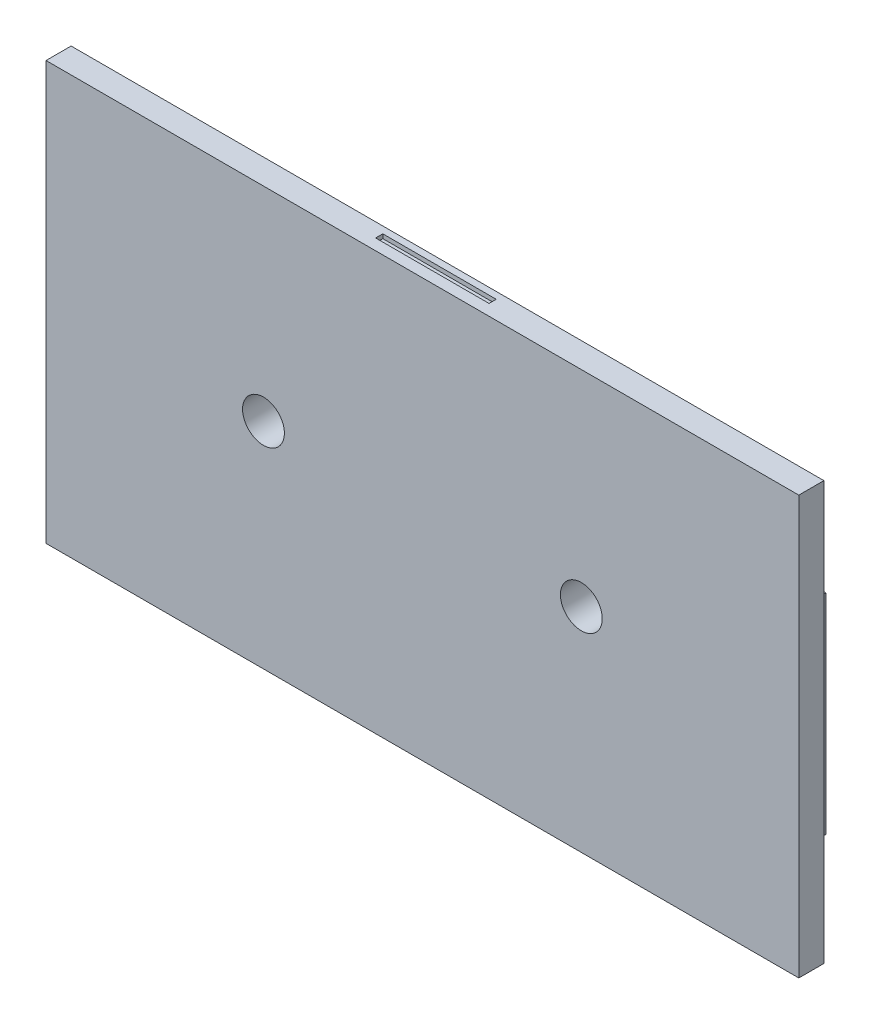
from build123d import *

# Parameters (mm, degrees)
SCHIZZO1_W                   = 180
SCHIZZO1_H                   = 100
SCHIZZO1_W_2                 = 170
SCHIZZO1_H_2                 = 90
ESTRUSIONE_ESTRUSIONE1_DEPTH = 6
SCHIZZO2_W                   = 0.85
SCHIZZO2_H                   = 100
ESTRUSIONE_ESTRUSIONE2_DEPTH = 170
SCHIZZO3_R                   = 12.5
SCHIZZO3_R_2                 = 9.25
ESTRUSIONE_ESTRUSIONE3_DEPTH = 10
SCHIZZO4_R                   = 5
TAGLIO_ESTRUSIONE1_DEPTH     = 30
SCHIZZO5_W                   = 2
SCHIZZO5_H                   = 50
ESTRUSIONE_ESTRUSIONE4_DEPTH = 2
SCHIZZO10_R                  = 9.25
SCHIZZO10_R_2                = 5
ESTRUSIONE_ESTRUSIONE7_DEPTH = 8.5
SCHIZZO11_R                  = 9.25
SCHIZZO11_R_2                = 5
ESTRUSIONE_ESTRUSIONE8_DEPTH = 8.5
SCHIZZO12_W                  = 27.111147563
SCHIZZO12_H                  = 1.71831217
TAGLIO_ESTRUSIONE2_DEPTH     = 1


with BuildPart() as part:
    # Schizzo1 → Estrusione-Estrusione1 (new body)
    with BuildSketch(Plane.XY):
        Rectangle(SCHIZZO1_W, SCHIZZO1_H)
        Rectangle(SCHIZZO1_W_2, SCHIZZO1_H_2, mode=Mode.SUBTRACT)
    extrude(amount=ESTRUSIONE_ESTRUSIONE1_DEPTH)

    # Schizzo2 → Estrusione-Estrusione2 (add)
    with BuildSketch(Plane(origin=(-85, 0, 0), x_dir=(0, 0, -1), z_dir=(1, 0, 0))):
        with Locations((-5.575, 0)):
            Rectangle(SCHIZZO2_W, SCHIZZO2_H)
    extrude(amount=ESTRUSIONE_ESTRUSIONE2_DEPTH)

    # Schizzo3 → Estrusione-Estrusione3 (add)
    with BuildSketch(Plane(origin=(0, 0, 5.15), x_dir=(-1, 0, 0), z_dir=(0, 0, -1))):
        with Locations((-38, 0.9)):
            Circle(SCHIZZO3_R)
        with Locations((-38, 0.9)):
            Circle(SCHIZZO3_R_2, mode=Mode.SUBTRACT)
        with Locations((38, 1.3)):
            Circle(SCHIZZO3_R)
        with Locations((38, 1.3)):
            Circle(SCHIZZO3_R_2, mode=Mode.SUBTRACT)
    extrude(amount=ESTRUSIONE_ESTRUSIONE3_DEPTH)

    # Schizzo4 → Taglio-Estrusione1 (cut)
    with BuildSketch(Plane(origin=(0, 0, 5.15), x_dir=(-1, 0, 0), z_dir=(0, 0, -1))):
        with Locations((-38, 0.9)):
            Circle(SCHIZZO4_R)
        with Locations((38, 1.3)):
            Circle(SCHIZZO4_R)
    extrude(amount=-TAGLIO_ESTRUSIONE1_DEPTH, mode=Mode.SUBTRACT)

    # Schizzo5 → Estrusione-Estrusione4 (add)
    with BuildSketch(Plane(origin=(0, 0, 0), x_dir=(-1, 0, 0), z_dir=(0, 0, -1))):
        with Locations((-87.5, 0)):
            Rectangle(SCHIZZO5_W, SCHIZZO5_H)
    estrusione_estrusione4 = extrude(amount=ESTRUSIONE_ESTRUSIONE4_DEPTH)

    # Specchia1: Estrusione-Estrusione4 across plane
    add(estrusione_estrusione4.mirror(Plane.ZY))

    # Schizzo10 → Estrusione-Estrusione7 (add)
    with BuildSketch(Plane(origin=(0, 0, 5.15), x_dir=(-1, 0, 0), z_dir=(0, 0, -1))):
        with Locations((-38, 0.9)):
            Circle(SCHIZZO10_R)
        with Locations((-38, 0.9)):
            Circle(SCHIZZO10_R_2, mode=Mode.SUBTRACT)
    extrude(amount=ESTRUSIONE_ESTRUSIONE7_DEPTH)

    # Schizzo11 → Estrusione-Estrusione8 (add)
    with BuildSketch(Plane(origin=(0, 0, 5.15), x_dir=(-1, 0, 0), z_dir=(0, 0, -1))):
        with Locations((38, 1.3)):
            Circle(SCHIZZO11_R)
        with Locations((38, 1.3)):
            Circle(SCHIZZO11_R_2, mode=Mode.SUBTRACT)
    extrude(amount=ESTRUSIONE_ESTRUSIONE8_DEPTH)

    # Schizzo12 → Taglio-Estrusione2 (cut)
    with BuildSketch(Plane(origin=(0, 50, 0), x_dir=(1, 0, 0), z_dir=(0, 1, 0))):
        with Locations((-0.286385361, -2.484235744)):
            Rectangle(SCHIZZO12_W, SCHIZZO12_H)
    extrude(amount=-TAGLIO_ESTRUSIONE2_DEPTH, mode=Mode.SUBTRACT)


solid = part.part
